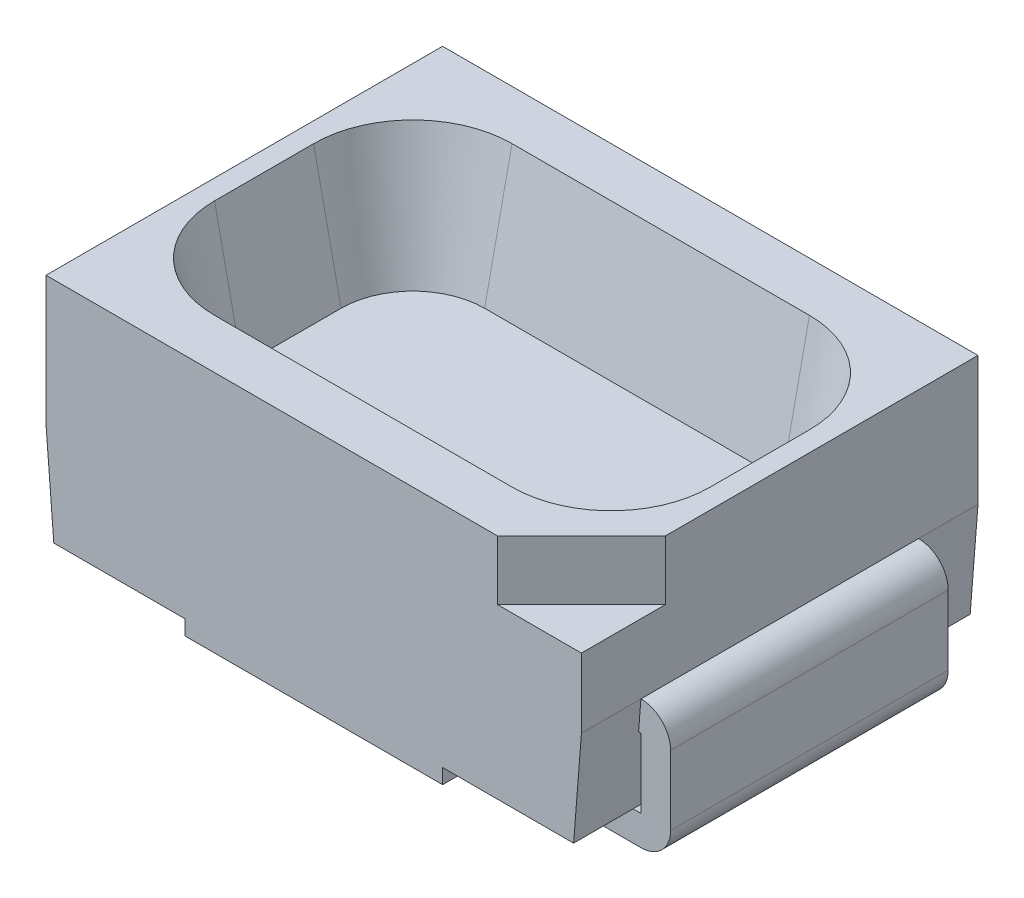
from build123d import *

# Parameters (mm, degrees)
EXTRUDE1_DEPTH     = 1
CUT_EXTRUDE1_DEPTH = 0.65
CUT_EXTRUDE1_DRAFT = -12
EXTRUDE2_DEPTH     = 0.7
CUT_EXTRUDE2_DEPTH = 0.3


with BuildPart() as part:
    # Sketch1 → Extrude1 (new body, symmetric)
    with BuildSketch(Plane.XY):
        Polygon((1.3501308, 0.65), (-1.3501308, 0.65), (-1.3501308, 0), (-1.310779947, -0.5), (-0.65, -0.5), (-0.65, -0.575), (0.65, -0.575), (0.65, -0.5), (1.310779947, -0.5), (1.3501308, 0), align=None)
    extrude(amount=EXTRUDE1_DEPTH, both=True)


with BuildPart() as cut_extrude1_tool:
    # Sketch4 → Cut-Extrude1 (with draft: the straight prism first)
    with BuildSketch(Plane(origin=(0, 0.65, 0), x_dir=(-1, 0, 0), z_dir=(0, 1, 0))):
        with BuildLine():
            ThreePointArc((0.75, -0.75), (1.103553391, -0.603553391), (1.25, -0.25))
            Line((1.25, -0.25), (1.25, 0.25))
            ThreePointArc((1.25, 0.25), (1.103553391, 0.603553391), (0.75, 0.75))
            Line((0.75, 0.75), (-0.75, 0.75))
            ThreePointArc((-0.75, 0.75), (-1.103553391, 0.603553391), (-1.25, 0.25))
            Line((-1.25, 0.25), (-1.25, -0.25))
            ThreePointArc((-1.25, -0.25), (-1.103553391, -0.603553391), (-0.75, -0.75))
            Line((-0.75, -0.75), (0.75, -0.75))
        make_face()
    extrude(amount=-CUT_EXTRUDE1_DEPTH)
    # Cut-Extrude1: the draft: its side faces are tilted about the plane it starts from
    cut_extrude1_sides = [cut_extrude1_tool.faces().sort_by_distance(p)[0] for p in [
        (1.103553391, 0.325, -0.603553391),
        (0, 0.325, -0.75),
        (-1.103553391, 0.325, -0.603553391),
        (-1.25, 0.325, 0),
        (-1.103553391, 0.325, 0.603553391),
        (0, 0.325, 0.75),
        (1.103553391, 0.325, 0.603553391),
        (1.25, 0.325, 0),
    ]]
    draft(cut_extrude1_sides, Plane(origin=(0, 0.65, 0), x_dir=(-1, 0, 0), z_dir=(0, 1, 0)), CUT_EXTRUDE1_DRAFT)


with BuildPart() as part_1:
    add(part.part)

    # Cut-Extrude1: cut by cut_extrude1_tool
    add(cut_extrude1_tool.part, mode=Mode.SUBTRACT)

    # Sketch1_3 → Extrude2 (add, symmetric)
    with BuildSketch(Plane.XY):
        with BuildLine():
            Line((-1.338325544, -0.15), (-1.3501308, 0))
            ThreePointArc((-1.3501308, -5.7e-08), (-1.456112252, -0.043980238), (-1.5, -0.15))
            Line((-1.5, -0.15), (-1.5, -0.5))
            ThreePointArc((-1.5, -0.5), (-1.456066017, -0.606066017), (-1.35, -0.65))
            Line((-1.35, -0.65), (-0.75, -0.65))
            Line((-0.75, -0.65), (-0.75, -0.5))
            Line((-0.75, -0.5), (-1.35, -0.5))
            Line((-1.35, -0.5), (-1.35, -0.15))
            Line((-1.35, -0.15), (-1.338325544, -0.15))
        make_face()
        with BuildLine():
            ThreePointArc((1.5, -0.15), (1.456112252, -0.043980238), (1.3501308, -5.7e-08))
            Line((1.3501308, 0), (1.338325544, -0.15))
            Line((1.338325544, -0.15), (1.35, -0.15))
            Line((1.35, -0.15), (1.35, -0.5))
            Line((1.35, -0.5), (0.75, -0.5))
            Line((0.75, -0.5), (0.75, -0.65))
            Line((0.75, -0.65), (1.35, -0.65))
            ThreePointArc((1.35, -0.65), (1.456066017, -0.606066017), (1.5, -0.5))
            Line((1.5, -0.5), (1.5, -0.15))
        make_face()
    extrude(amount=EXTRUDE2_DEPTH, both=True)

    # Sketch4_5 → Cut-Extrude2 (cut)
    with BuildSketch(Plane(origin=(0, 0.65, 0), x_dir=(-1, 0, 0), z_dir=(0, 1, 0))):
        Polygon((-1.3501308, 1), (-1.3501308, 0.575735931), (-0.925866731, 1), align=None)
    extrude(amount=-CUT_EXTRUDE2_DEPTH, mode=Mode.SUBTRACT)


solid = part_1.part
